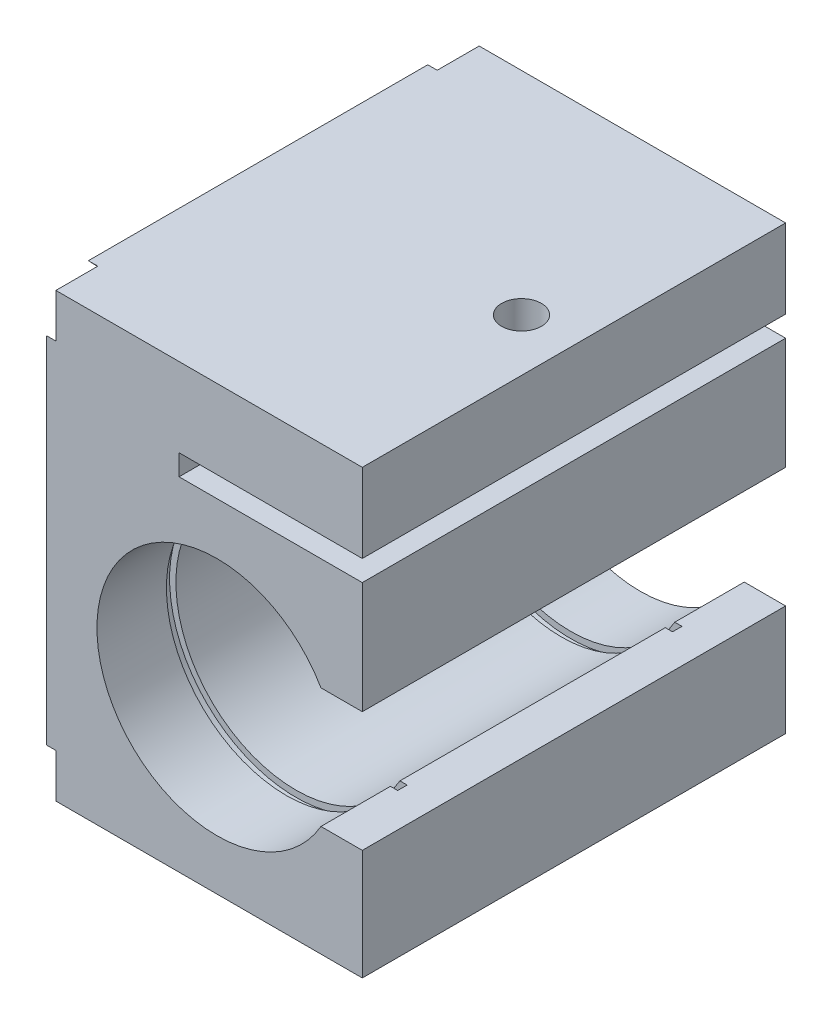
from build123d import *

# Parameters (mm, degrees)
SKETCH11_W          = 50
SKETCH11_H          = 70
BOSS_EXTRUDE4_DEPTH = 67
SKETCH12_W          = 29
SKETCH12_H          = 3.3
CUT_EXTRUDE7_DEPTH  = 68
CUT_EXTRUDE8_DEPTH  = 1.5
SKETCH14_R          = 3.15
CUT_EXTRUDE9_DEPTH  = 12.5
SKETCH15_R          = 20
CUT_EXTRUDE11_DEPTH = 1.5


with BuildPart() as part:
    # Sketch11 → Boss-Extrude4 (new body)
    with BuildSketch(Plane.XY):
        Rectangle(SKETCH11_W, SKETCH11_H)
    extrude(amount=BOSS_EXTRUDE4_DEPTH)

    # Sketch12 → Cut-Extrude7 (cut, through all)
    with BuildSketch(Plane.XY.offset(67)):
        with Locations((10.5, 20.85)):
            Rectangle(SKETCH12_W, SKETCH12_H)
        with BuildLine():
            Line((18.454482672, -17.5), (25, -17.5))
            Line((25, -17.5), (25, 1.5))
            Line((25, 1.5), (18.454482672, 1.5))
            ThreePointArc((18.454482672, 1.5), (-17, -8), (18.454482672, -17.5))
        make_face()
    extrude(amount=-CUT_EXTRUDE7_DEPTH, mode=Mode.SUBTRACT)

    # Sketch13 → Cut-Extrude8 (cut)
    with BuildSketch(Plane.ZY.offset(25)):
        Polygon((0, 35), (0, 28.058135949), (26.855644409, 0), (0, -28.058135949), (0, -35), (6.644355591, -35), (33.5, -6.941864051), (60.355644409, -35), (67, -35), (67, -28.058135949), (40.144355591, 0), (67, 28.058135949), (67, 35), (60.355644409, 35), (33.5, 6.941864051), (6.644355591, 35), align=None)
    extrude(amount=-CUT_EXTRUDE8_DEPTH, mode=Mode.SUBTRACT)

    # Sketch14 → Cut-Extrude9 (cut)
    with BuildSketch(Plane(origin=(0, 35, 0), x_dir=(1, 0, 0), z_dir=(0, 1, 0))):
        with Locations((16.7, -33.5)):
            Circle(SKETCH14_R)
    extrude(amount=-CUT_EXTRUDE9_DEPTH, mode=Mode.SUBTRACT)

    # Sketch15 → Cut-Extrude11 (cut)
    with BuildSketch(Plane.XY.offset(54.5)):
        with Locations((2, -8)):
            Circle(SKETCH15_R)
    cut_extrude11 = extrude(amount=CUT_EXTRUDE11_DEPTH, mode=Mode.SUBTRACT)

    # Mirror4: Cut-Extrude11 across plane
    add(cut_extrude11.mirror(Plane.XY.offset(33.5)), mode=Mode.SUBTRACT)


solid = part.part
